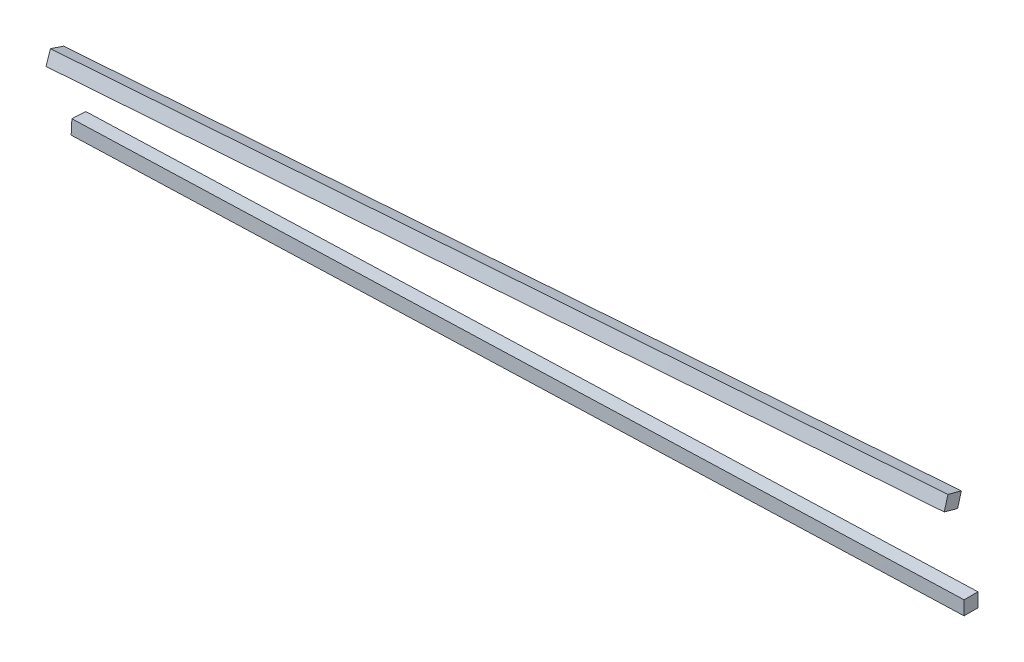
from build123d import *


with BuildPart() as part:
    # Sketch1_3 → Loft2 section 0
    with BuildSketch(Plane(origin=(0, 0, 0), x_dir=(0, 0, -1), z_dir=(1, 0, 0))):
        Polygon((73.722592843, -17.689285792), (78.376128634, -18.967910303), (79.654753145, -14.314374511), (75.001217353, -13.035750001), align=None)
    # Sketch2_3 → Loft2 section 1
    with BuildSketch(Plane(origin=(-301.244, 0, 0), x_dir=(0, 0, -1), z_dir=(1, 0, 0))):
        Polygon((67.679850957, -30.564309841), (63.101919005, -29.03695427), (64.629274577, -24.459022317), (69.207206529, -25.986377889), align=None)
    loft()


with BuildPart() as body_2:
    # Sketch1_6 → Loft5 section 0
    with BuildSketch(Plane(origin=(0, 0, 0), x_dir=(0, 0, -1), z_dir=(1, 0, 0))):
        Polygon((80.606015408, -52.363936617), (85.432011787, -52.369848162), (85.437923333, -47.543851783), (80.611926953, -47.537940238), align=None)
    # Sketch2_8 → Loft5 section 1
    with BuildSketch(Plane(origin=(-301.244, 0, 0), x_dir=(0, 0, -1), z_dir=(1, 0, 0))):
        Polygon((76.656597753, -54.31319682), (71.836959606, -54.065478974), (72.084677452, -49.245840827), (76.904315599, -49.493558673), align=None)
    loft()


solid = Compound([part.part, body_2.part])
